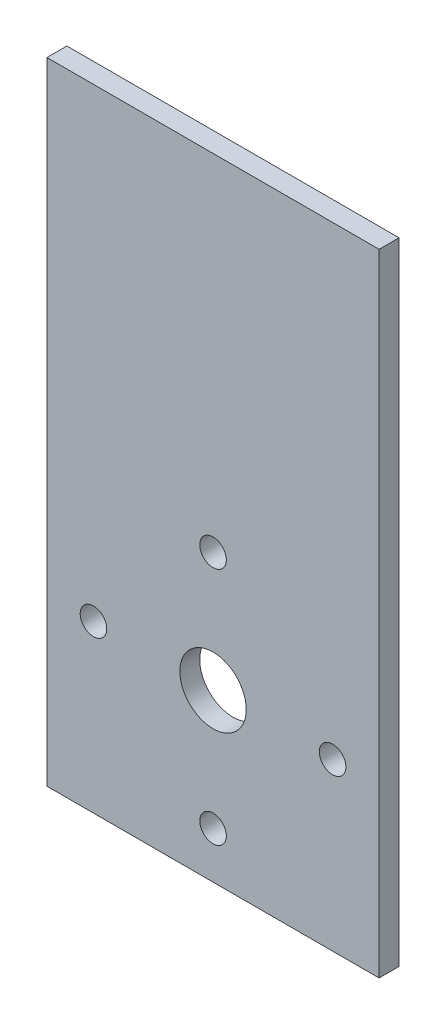
from build123d import *

# Parameters (mm, degrees)
SKETCH1_W           = 50
SKETCH1_H           = 95
SKETCH1_R           = 5
BOSS_EXTRUDE1_DEPTH = 3
SKETCH2_R           = 2
CUT_EXTRUDE3_DEPTH  = 10


with BuildPart() as part:
    # Sketch1 → Boss-Extrude1 (new body)
    with BuildSketch(Plane.XY):
        with Locations((0, 47.5)):
            Rectangle(SKETCH1_W, SKETCH1_H)
        with Locations((0, 25)):
            Circle(SKETCH1_R, mode=Mode.SUBTRACT)
    extrude(amount=BOSS_EXTRUDE1_DEPTH)

    # Sketch2 → Cut-Extrude3 (cut)
    with BuildSketch(Plane.XY.offset(3)):
        with Locations((0, 43)):
            Circle(SKETCH2_R)
        with Locations((18, 25)):
            Circle(SKETCH2_R)
        with Locations((0, 7)):
            Circle(SKETCH2_R)
        with Locations((-18, 25)):
            Circle(SKETCH2_R)
    extrude(amount=-CUT_EXTRUDE3_DEPTH, mode=Mode.SUBTRACT)


solid = part.part
